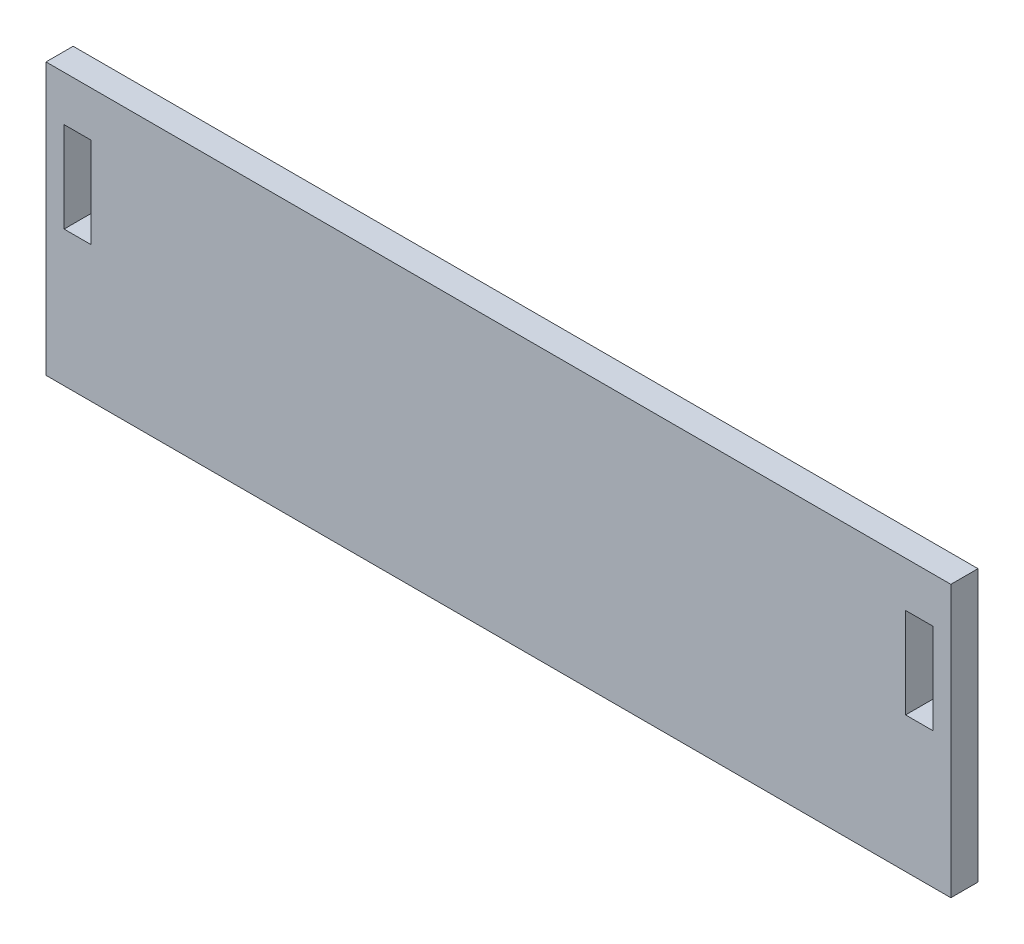
from build123d import *

# Parameters (mm, degrees)
SKETCH1_W           = 100
SKETCH1_H           = 30
SKETCH1_W_2         = 3
SKETCH1_H_2         = 10
BOSS_EXTRUDE1_DEPTH = 3


with BuildPart() as part:
    # Sketch1 → Boss-Extrude1 (new body)
    with BuildSketch(Plane.XY):
        Rectangle(SKETCH1_W, SKETCH1_H)
        with Locations((-46.5, 5)):
            Rectangle(SKETCH1_W_2, SKETCH1_H_2, mode=Mode.SUBTRACT)
        with Locations((46.5, 5)):
            Rectangle(SKETCH1_W_2, SKETCH1_H_2, mode=Mode.SUBTRACT)
    extrude(amount=BOSS_EXTRUDE1_DEPTH)


solid = part.part
